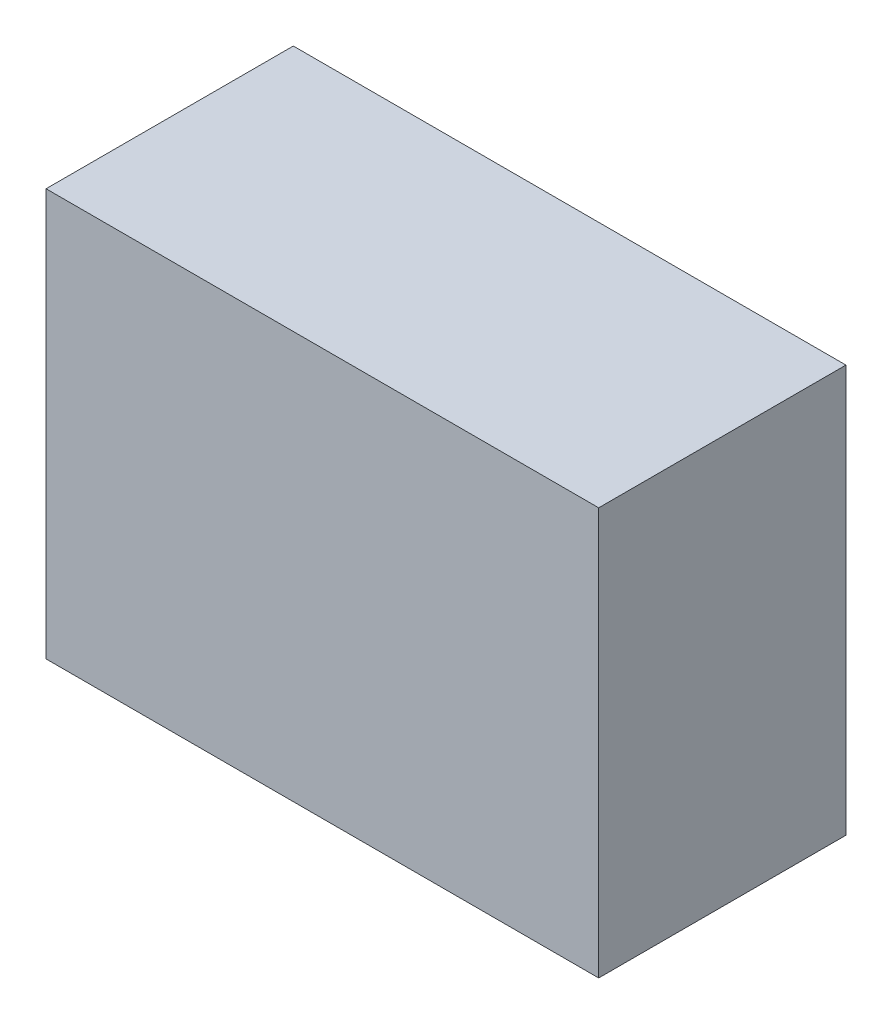
from build123d import *

# Parameters (mm, degrees)
SKETCH_1_W      = 3.8
SKETCH_1_H      = 2.8
EXTRUDE_1_DEPTH = 1.7


with BuildPart() as part:
    # Эскиз1 → Бобышка-Вытянуть1 (new body)
    with BuildSketch(Plane.XY):
        Rectangle(SKETCH_1_W, SKETCH_1_H)
    extrude(amount=EXTRUDE_1_DEPTH)


solid = part.part
